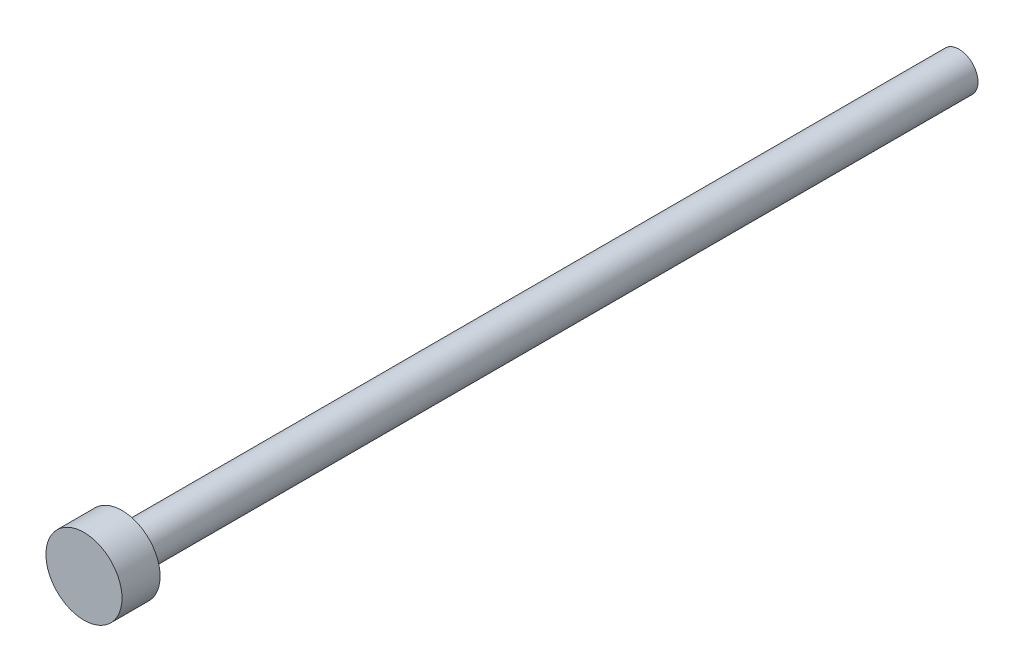
from build123d import *

# Parameters (mm, degrees)
SKETCH2_R           = 0.5
BOSS_EXTRUDE2_DEPTH = 22
SKETCH3_R           = 1
BOSS_EXTRUDE3_DEPTH = 1


with BuildPart() as part:
    # Sketch2 → Boss-Extrude2 (new body)
    with BuildSketch(Plane.XY):
        Circle(SKETCH2_R)
    extrude(amount=BOSS_EXTRUDE2_DEPTH)

    # Sketch3 → Boss-Extrude3 (add)
    with BuildSketch(Plane.XY.offset(22)):
        Circle(SKETCH3_R)
    extrude(amount=BOSS_EXTRUDE3_DEPTH)


solid = part.part
